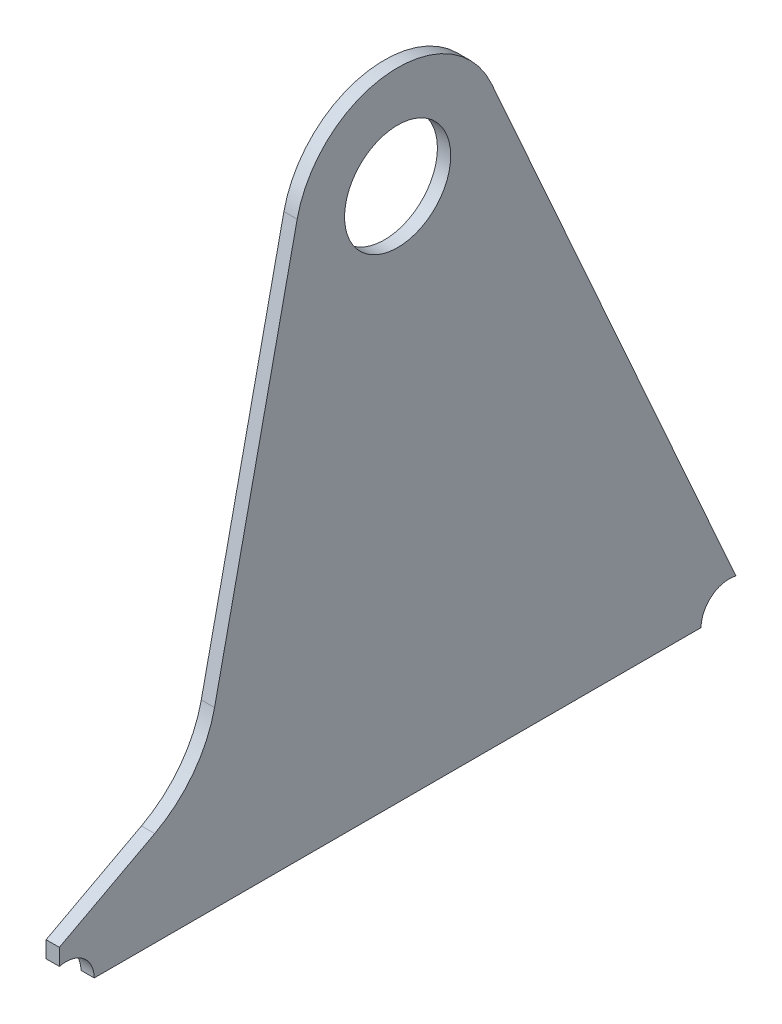
from build123d import *

# Parameters (mm, degrees)
EXTRUDE_1_DEPTH      = 2
EXTRUDE_1_DEPTH_BACK = 2
SKETCH_1_R           = 16


with BuildPart() as part:
    # Эскиз1 → Бобышка-Вытянуть1 (new, two sides: drawn at the far end of the back side and taken through both)
    with BuildSketch(Plane(origin=(0, 0, 0), x_dir=(0, 0, -1), z_dir=(1, 0, 0)).offset(-EXTRUDE_1_DEPTH_BACK)):
        with BuildLine():
            Line((-91.5, -161), (91.5, -161))
            ThreePointArc((91.5, -161), (94.74405099, -154.319805392), (102, -152.738644179))
            Line((102, -152.738644179), (28.315921349, 12.617788956))
            ThreePointArc((28.315921349, 12.617788956), (-3.187422672, 30.835699063), (-30.298183379, 6.55896973))
            Line((-30.298183379, 6.55896973), (-55.212875562, -108.530738505))
            ThreePointArc((-55.212875562, -108.530738505), (-61.600879697, -122.455675592), (-73.25038996, -132.405518825))
            Line((-73.25038996, -132.405518825), (-102, -147.738644179))
            Line((-102, -147.738644179), (-102, -152.738644179))
            ThreePointArc((-102, -152.738644179), (-94.74405099, -154.319805392), (-91.5, -161))
        make_face()
        Circle(SKETCH_1_R, mode=Mode.SUBTRACT)
    extrude(amount=EXTRUDE_1_DEPTH + EXTRUDE_1_DEPTH_BACK)


solid = part.part
